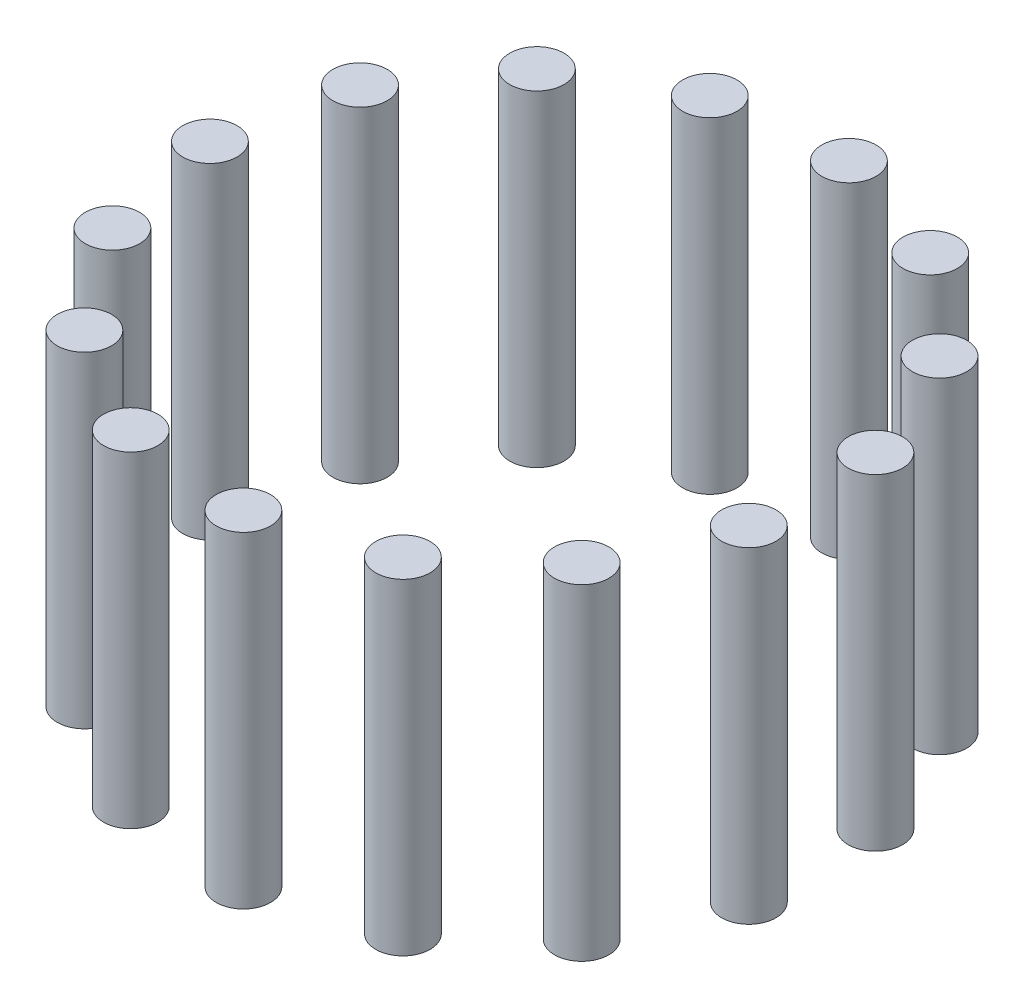
from build123d import *

# Parameters (mm, degrees)
SKETCH1_R              = 2.5
BOSS_EXTRUDE1_DEPTH    = 30
BOSS_EXTRUDE1_2_DEPTH  = 30
BOSS_EXTRUDE1_3_DEPTH  = 30
BOSS_EXTRUDE1_4_DEPTH  = 30
BOSS_EXTRUDE1_5_DEPTH  = 30
BOSS_EXTRUDE1_6_DEPTH  = 30
BOSS_EXTRUDE1_7_DEPTH  = 30
BOSS_EXTRUDE1_8_DEPTH  = 30
BOSS_EXTRUDE1_9_DEPTH  = 30
BOSS_EXTRUDE1_10_DEPTH = 30
BOSS_EXTRUDE1_11_DEPTH = 30
BOSS_EXTRUDE1_12_DEPTH = 30
BOSS_EXTRUDE1_13_DEPTH = 30
BOSS_EXTRUDE1_14_DEPTH = 30
BOSS_EXTRUDE1_15_DEPTH = 30


with BuildPart() as part:
    # Sketch1 → Boss-Extrude1 (new body)
    with BuildSketch(Plane(origin=(0, 0, 0), x_dir=(1, 0, 0), z_dir=(0, 1, 0))):
        with Locations((27.388132821, 5.821527343)):
            Circle(SKETCH1_R)
    extrude(amount=BOSS_EXTRUDE1_DEPTH)


with BuildPart() as body_2:
    # Sketch1 → Boss-Extrude1 2 (new body)
    with BuildSketch(Plane(origin=(0, 0, 0), x_dir=(1, 0, 0), z_dir=(0, 1, 0))):
        with Locations((27.388132821, -5.821527343)):
            Circle(SKETCH1_R)
    extrude(amount=BOSS_EXTRUDE1_2_DEPTH)


with BuildPart() as body_3:
    # Sketch1 → Boss-Extrude1 3 (new body)
    with BuildSketch(Plane(origin=(0, 0, 0), x_dir=(1, 0, 0), z_dir=(0, 1, 0))):
        with Locations((22.652475842, -16.457987064)):
            Circle(SKETCH1_R)
    extrude(amount=BOSS_EXTRUDE1_3_DEPTH)


with BuildPart() as body_4:
    # Sketch1 → Boss-Extrude1 4 (new body)
    with BuildSketch(Plane(origin=(0, 0, 0), x_dir=(1, 0, 0), z_dir=(0, 1, 0))):
        with Locations((14, -24.248711306)):
            Circle(SKETCH1_R)
    extrude(amount=BOSS_EXTRUDE1_4_DEPTH)


with BuildPart() as body_5:
    # Sketch1 → Boss-Extrude1 5 (new body)
    with BuildSketch(Plane(origin=(0, 0, 0), x_dir=(1, 0, 0), z_dir=(0, 1, 0))):
        with Locations((2.926796971, -27.84661307)):
            Circle(SKETCH1_R)
    extrude(amount=BOSS_EXTRUDE1_5_DEPTH)


with BuildPart() as body_6:
    # Sketch1 → Boss-Extrude1 6 (new body)
    with BuildSketch(Plane(origin=(0, 0, 0), x_dir=(1, 0, 0), z_dir=(0, 1, 0))):
        with Locations((-8.652475842, -26.629582456)):
            Circle(SKETCH1_R)
    extrude(amount=BOSS_EXTRUDE1_6_DEPTH)


with BuildPart() as body_7:
    # Sketch1 → Boss-Extrude1 7 (new body)
    with BuildSketch(Plane(origin=(0, 0, 0), x_dir=(1, 0, 0), z_dir=(0, 1, 0))):
        with Locations((-18.735656978, -20.808055113)):
            Circle(SKETCH1_R)
    extrude(amount=BOSS_EXTRUDE1_7_DEPTH)


with BuildPart() as body_8:
    # Sketch1 → Boss-Extrude1 8 (new body)
    with BuildSketch(Plane(origin=(0, 0, 0), x_dir=(1, 0, 0), z_dir=(0, 1, 0))):
        with Locations((-25.579272814, -11.388626006)):
            Circle(SKETCH1_R)
    extrude(amount=BOSS_EXTRUDE1_8_DEPTH)


with BuildPart() as body_9:
    # Sketch1 → Boss-Extrude1 9 (new body)
    with BuildSketch(Plane(origin=(0, 0, 0), x_dir=(1, 0, 0), z_dir=(0, 1, 0))):
        with Locations((-28, 0)):
            Circle(SKETCH1_R)
    extrude(amount=BOSS_EXTRUDE1_9_DEPTH)


with BuildPart() as body_10:
    # Sketch1 → Boss-Extrude1 10 (new body)
    with BuildSketch(Plane(origin=(0, 0, 0), x_dir=(1, 0, 0), z_dir=(0, 1, 0))):
        with Locations((-25.579272814, 11.388626006)):
            Circle(SKETCH1_R)
    extrude(amount=BOSS_EXTRUDE1_10_DEPTH)


with BuildPart() as body_11:
    # Sketch1 → Boss-Extrude1 11 (new body)
    with BuildSketch(Plane(origin=(0, 0, 0), x_dir=(1, 0, 0), z_dir=(0, 1, 0))):
        with Locations((-18.735656978, 20.808055113)):
            Circle(SKETCH1_R)
    extrude(amount=BOSS_EXTRUDE1_11_DEPTH)


with BuildPart() as body_12:
    # Sketch1 → Boss-Extrude1 12 (new body)
    with BuildSketch(Plane(origin=(0, 0, 0), x_dir=(1, 0, 0), z_dir=(0, 1, 0))):
        with Locations((-8.652475842, 26.629582456)):
            Circle(SKETCH1_R)
    extrude(amount=BOSS_EXTRUDE1_12_DEPTH)


with BuildPart() as body_13:
    # Sketch1 → Boss-Extrude1 13 (new body)
    with BuildSketch(Plane(origin=(0, 0, 0), x_dir=(1, 0, 0), z_dir=(0, 1, 0))):
        with Locations((2.926796971, 27.84661307)):
            Circle(SKETCH1_R)
    extrude(amount=BOSS_EXTRUDE1_13_DEPTH)


with BuildPart() as body_14:
    # Sketch1 → Boss-Extrude1 14 (new body)
    with BuildSketch(Plane(origin=(0, 0, 0), x_dir=(1, 0, 0), z_dir=(0, 1, 0))):
        with Locations((14, 24.248711306)):
            Circle(SKETCH1_R)
    extrude(amount=BOSS_EXTRUDE1_14_DEPTH)


with BuildPart() as body_15:
    # Sketch1 → Boss-Extrude1 15 (new body)
    with BuildSketch(Plane(origin=(0, 0, 0), x_dir=(1, 0, 0), z_dir=(0, 1, 0))):
        with Locations((22.652475842, 16.457987064)):
            Circle(SKETCH1_R)
    extrude(amount=BOSS_EXTRUDE1_15_DEPTH)


solid = Compound([part.part, body_2.part, body_3.part, body_4.part, body_5.part, body_6.part, body_7.part, body_8.part, body_9.part, body_10.part, body_11.part, body_12.part, body_13.part, body_14.part, body_15.part])
